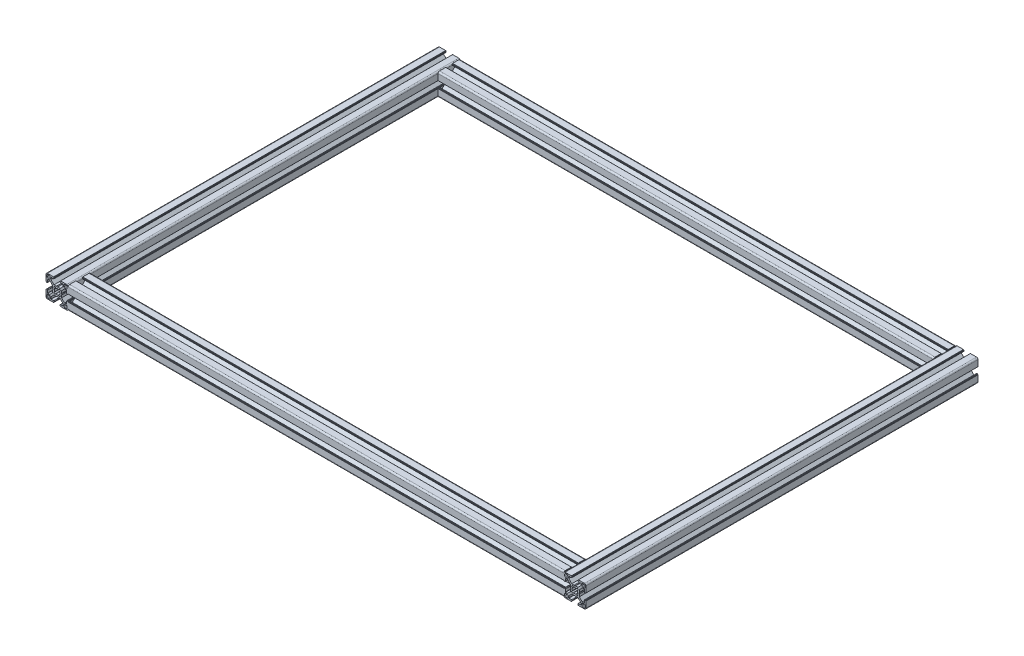
from build123d import *

# Parameters (mm, degrees)
BOSS_EXTRUDE1_DEPTH   = 265
BOSS_EXTRUDE1_2_DEPTH = 265
BOSS_EXTRUDE2_DEPTH   = 335


with BuildPart() as part:
    # Sketch13 → Boss-Extrude1 (new body, symmetric)
    with BuildSketch(Plane.XY):
        with BuildLine():
            Line((356.00446543, 0.899999619), (355.484852164, 0))
            Line((355.484852164, 0), (356.00446543, -0.899999619))
            Line((356.00446543, -0.899999619), (356.00446543, -4.204465866))
            Line((356.00446543, -4.204465866), (360.049999564, -8.25))
            Line((360.049999564, -8.25), (362.59999928, -8.25))
            ThreePointArc((362.59999928, -8.25), (362.741420837, -8.191421273), (362.799999564, -8.049999716))
            Line((362.799999564, -8.049999716), (362.799999564, -4.649999613))
            ThreePointArc((362.799999564, -4.649999613), (362.975735606, -4.225735278), (363.39999994, -4.049999237))
            Line((363.39999994, -4.049999237), (364.300000043, -4.049999237))
            ThreePointArc((364.300000043, -4.049999237), (364.4414216, -4.108577964), (364.500000327, -4.249999521))
            Line((364.500000327, -4.249999521), (364.500000327, -4.349998953))
            ThreePointArc((364.500000327, -4.349998953), (364.558579054, -4.49142051), (364.700000611, -4.549999237))
            Line((364.700000611, -4.549999237), (364.799999716, -4.549999237))
            ThreePointArc((364.799999716, -4.549999237), (364.941421273, -4.608577964), (365, -4.749999521))
            Line((365, -4.749999521), (365, -13.000000346))
            ThreePointArc((365, -13.000000346), (364.414213664, -14.414213664), (363.000000346, -15))
            Line((363.000000346, -15), (354.749999945, -15))
            ThreePointArc((354.749999945, -15), (354.60857832, -14.941421245), (354.549999564, -14.799999619))
            Line((354.549999564, -14.799999619), (354.549999564, -14.69999942))
            ThreePointArc((354.549999564, -14.69999942), (354.49142109, -14.558578474), (354.350000144, -14.5))
            Line((354.350000144, -14.5), (354.250000374, -14.5))
            ThreePointArc((354.250000374, -14.5), (354.108578753, -14.441421247), (354.05, -14.299999626))
            Line((354.05, -14.299999626), (354.05, -13.399999434))
            ThreePointArc((354.05, -13.399999434), (354.225735989, -12.975735226), (354.650000197, -12.799999237))
            Line((354.650000197, -12.799999237), (358.049999924, -12.799999237))
            ThreePointArc((358.049999924, -12.799999237), (358.191421565, -12.741420475), (358.250000327, -12.599998834))
            Line((358.250000327, -12.599998834), (358.250000327, -10.049999237))
            Line((358.250000327, -10.049999237), (354.204466193, -6))
            Line((354.204466193, -6), (350.899999946, -6))
            Line((350.899999946, -6), (350, -5.484851837))
            Line((350, -5.484851837), (349.100000054, -6))
            Line((349.100000054, -6), (345.795533807, -6))
            Line((345.795533807, -6), (341.749999673, -10.049999237))
            Line((341.749999673, -10.049999237), (341.749999673, -12.599998834))
            ThreePointArc((341.749999673, -12.599998834), (341.808578435, -12.741420475), (341.950000076, -12.799999237))
            Line((341.950000076, -12.799999237), (345.349999803, -12.799999237))
            ThreePointArc((345.349999803, -12.799999237), (345.774264011, -12.975735226), (345.95, -13.399999434))
            Line((345.95, -13.399999434), (345.95, -14.299999626))
            ThreePointArc((345.95, -14.299999626), (345.891421247, -14.441421247), (345.749999626, -14.5))
            Line((345.749999626, -14.5), (345.649999856, -14.5))
            ThreePointArc((345.649999856, -14.5), (345.50857891, -14.558578474), (345.450000436, -14.69999942))
            Line((345.450000436, -14.69999942), (345.450000436, -14.799999619))
            ThreePointArc((345.450000436, -14.799999619), (345.39142168, -14.941421245), (345.250000055, -15))
            Line((345.250000055, -15), (336.999999654, -15))
            ThreePointArc((336.999999654, -15), (335.585786336, -14.414213664), (335, -13.000000346))
            Line((335, -13.000000346), (335, -4.749999521))
            ThreePointArc((335, -4.749999521), (335.058578727, -4.608577964), (335.200000284, -4.549999237))
            Line((335.200000284, -4.549999237), (335.299999389, -4.549999237))
            ThreePointArc((335.299999389, -4.549999237), (335.441420946, -4.49142051), (335.499999673, -4.349998953))
            Line((335.499999673, -4.349998953), (335.499999673, -4.249999521))
            ThreePointArc((335.499999673, -4.249999521), (335.5585784, -4.108577964), (335.699999957, -4.049999237))
            Line((335.699999957, -4.049999237), (336.60000006, -4.049999237))
            ThreePointArc((336.60000006, -4.049999237), (337.024264394, -4.225735278), (337.200000436, -4.649999613))
            Line((337.200000436, -4.649999613), (337.200000436, -8.049999716))
            ThreePointArc((337.200000436, -8.049999716), (337.258579163, -8.191421273), (337.40000072, -8.25))
            Line((337.40000072, -8.25), (339.950000436, -8.25))
            Line((339.950000436, -8.25), (343.99553457, -4.204465866))
            Line((343.99553457, -4.204465866), (343.99553457, -0.899999619))
            Line((343.99553457, -0.899999619), (344.515147836, 0))
            Line((344.515147836, 0), (343.99553457, 0.899999619))
            Line((343.99553457, 0.899999619), (343.99553457, 4.204465866))
            Line((343.99553457, 4.204465866), (339.950000436, 8.25))
            Line((339.950000436, 8.25), (337.40000072, 8.25))
            ThreePointArc((337.40000072, 8.25), (337.258579163, 8.191421273), (337.200000436, 8.049999716))
            Line((337.200000436, 8.049999716), (337.200000436, 4.649999613))
            ThreePointArc((337.200000436, 4.649999613), (337.024264394, 4.225735278), (336.60000006, 4.049999237))
            Line((336.60000006, 4.049999237), (335.699999957, 4.049999237))
            ThreePointArc((335.699999957, 4.049999237), (335.5585784, 4.108577964), (335.499999673, 4.249999521))
            Line((335.499999673, 4.249999521), (335.499999673, 4.349998953))
            ThreePointArc((335.499999673, 4.349998953), (335.441420946, 4.49142051), (335.299999389, 4.549999237))
            Line((335.299999389, 4.549999237), (335.200000284, 4.549999237))
            ThreePointArc((335.200000284, 4.549999237), (335.058578727, 4.608577964), (335, 4.749999521))
            Line((335, 4.749999521), (335, 13.000000346))
            ThreePointArc((335, 13.000000346), (335.585786336, 14.414213664), (336.999999654, 15))
            Line((336.999999654, 15), (345.250000055, 15))
            ThreePointArc((345.250000055, 15), (345.39142168, 14.941421245), (345.450000436, 14.799999619))
            Line((345.450000436, 14.799999619), (345.450000436, 14.69999942))
            ThreePointArc((345.450000436, 14.69999942), (345.50857891, 14.558578474), (345.649999856, 14.5))
            Line((345.649999856, 14.5), (345.749999626, 14.5))
            ThreePointArc((345.749999626, 14.5), (345.891421247, 14.441421247), (345.95, 14.299999626))
            Line((345.95, 14.299999626), (345.95, 13.399999434))
            ThreePointArc((345.95, 13.399999434), (345.774264011, 12.975735226), (345.349999803, 12.799999237))
            Line((345.349999803, 12.799999237), (341.950000076, 12.799999237))
            ThreePointArc((341.950000076, 12.799999237), (341.808578435, 12.741420475), (341.749999673, 12.599998834))
            Line((341.749999673, 12.599998834), (341.749999673, 10.049999237))
            Line((341.749999673, 10.049999237), (345.795533807, 6))
            Line((345.795533807, 6), (349.100000054, 6))
            Line((349.100000054, 6), (350, 5.484851837))
            Line((350, 5.484851837), (350.899999946, 6))
            Line((350.899999946, 6), (354.204466193, 6))
            Line((354.204466193, 6), (358.250000327, 10.049999237))
            Line((358.250000327, 10.049999237), (358.250000327, 12.599998834))
            ThreePointArc((358.250000327, 12.599998834), (358.191421565, 12.741420475), (358.049999924, 12.799999237))
            Line((358.049999924, 12.799999237), (354.650000197, 12.799999237))
            ThreePointArc((354.650000197, 12.799999237), (354.225735989, 12.975735226), (354.05, 13.399999434))
            Line((354.05, 13.399999434), (354.05, 14.299999626))
            ThreePointArc((354.05, 14.299999626), (354.108578753, 14.441421247), (354.250000374, 14.5))
            Line((354.250000374, 14.5), (354.350000144, 14.5))
            ThreePointArc((354.350000144, 14.5), (354.49142109, 14.558578474), (354.549999564, 14.69999942))
            Line((354.549999564, 14.69999942), (354.549999564, 14.799999619))
            ThreePointArc((354.549999564, 14.799999619), (354.60857832, 14.941421245), (354.749999945, 15))
            Line((354.749999945, 15), (363.000000346, 15))
            ThreePointArc((363.000000346, 15), (364.414213664, 14.414213664), (365, 13.000000346))
            Line((365, 13.000000346), (365, 4.749999521))
            ThreePointArc((365, 4.749999521), (364.941421273, 4.608577964), (364.799999716, 4.549999237))
            Line((364.799999716, 4.549999237), (364.700000611, 4.549999237))
            ThreePointArc((364.700000611, 4.549999237), (364.558579054, 4.49142051), (364.500000327, 4.349998953))
            Line((364.500000327, 4.349998953), (364.500000327, 4.249999521))
            ThreePointArc((364.500000327, 4.249999521), (364.4414216, 4.108577964), (364.300000043, 4.049999237))
            Line((364.300000043, 4.049999237), (363.39999994, 4.049999237))
            ThreePointArc((363.39999994, 4.049999237), (362.975735606, 4.225735278), (362.799999564, 4.649999613))
            Line((362.799999564, 4.649999613), (362.799999564, 8.049999716))
            ThreePointArc((362.799999564, 8.049999716), (362.741420837, 8.191421273), (362.59999928, 8.25))
            Line((362.59999928, 8.25), (360.049999564, 8.25))
            Line((360.049999564, 8.25), (356.00446543, 4.204465866))
            Line((356.00446543, 4.204465866), (356.00446543, 0.899999619))
        make_face()
        with BuildLine():
            Line((363.70000109, 12.700000408), (363.70000109, 10.499999626))
            ThreePointArc((363.70000109, 10.499999626), (363.407107874, 9.792892851), (362.7000011, 9.499999635))
            Line((362.7000011, 9.499999635), (360.500000318, 9.499999635))
            ThreePointArc((360.500000318, 9.499999635), (359.792893543, 9.792892851), (359.500000327, 10.499999626))
            Line((359.500000327, 10.499999626), (359.500000327, 12.700000408))
            ThreePointArc((359.500000327, 12.700000408), (359.792893543, 13.407107182), (360.500000318, 13.700000398))
            Line((360.500000318, 13.700000398), (362.7000011, 13.700000398))
            ThreePointArc((362.7000011, 13.700000398), (363.407107874, 13.407107182), (363.70000109, 12.700000408))
        make_face(mode=Mode.SUBTRACT)
        with BuildLine():
            Line((353.135929412, 4.518400903), (351.600129524, 3.280561767))
            ThreePointArc((351.600129524, 3.280561767), (350, 3.65), (348.399870476, 3.280561767))
            Line((348.399870476, 3.280561767), (346.864070588, 4.518400903))
            ThreePointArc((346.864070588, 4.518400903), (346.118997741, 3.897155561), (345.494663108, 3.154669473))
            Line((345.494663108, 3.154669473), (346.719438268, 1.600129597))
            ThreePointArc((346.719438268, 1.600129597), (346.35, 0), (346.719438268, -1.600129597))
            Line((346.719438268, -1.600129597), (345.494663108, -3.154669473))
            ThreePointArc((345.494663108, -3.154669473), (346.118997741, -3.897155561), (346.864070588, -4.518400903))
            Line((346.864070588, -4.518400903), (348.399870476, -3.280561767))
            ThreePointArc((348.399870476, -3.280561767), (350, -3.65), (351.600129524, -3.280561767))
            Line((351.600129524, -3.280561767), (353.135929412, -4.518400903))
            ThreePointArc((353.135929412, -4.518400903), (353.881002259, -3.897155561), (354.505336892, -3.154669473))
            Line((354.505336892, -3.154669473), (353.280561732, -1.600129597))
            ThreePointArc((353.280561732, -1.600129597), (353.65, 0), (353.280561732, 1.600129597))
            Line((353.280561732, 1.600129597), (354.505336892, 3.154669473))
            ThreePointArc((354.505336892, 3.154669473), (353.881002259, 3.897155561), (353.135929412, 4.518400903))
        make_face(mode=Mode.SUBTRACT)
        with BuildLine():
            Line((336.29999891, -12.700000408), (336.29999891, -10.499999626))
            ThreePointArc((336.29999891, -10.499999626), (336.592892126, -9.792892851), (337.2999989, -9.499999635))
            Line((337.2999989, -9.499999635), (339.499999682, -9.499999635))
            ThreePointArc((339.499999682, -9.499999635), (340.207106457, -9.792892851), (340.499999673, -10.499999626))
            Line((340.499999673, -10.499999626), (340.499999673, -12.700000408))
            ThreePointArc((340.499999673, -12.700000408), (340.207106457, -13.407107182), (339.499999682, -13.700000398))
            Line((339.499999682, -13.700000398), (337.2999989, -13.700000398))
            ThreePointArc((337.2999989, -13.700000398), (336.592892126, -13.407107182), (336.29999891, -12.700000408))
        make_face(mode=Mode.SUBTRACT)
        with BuildLine():
            Line((360.500000318, -13.700000398), (362.7000011, -13.700000398))
            ThreePointArc((362.7000011, -13.700000398), (363.407107874, -13.407107182), (363.70000109, -12.700000408))
            Line((363.70000109, -12.700000408), (363.70000109, -10.499999626))
            ThreePointArc((363.70000109, -10.499999626), (363.407107874, -9.792892851), (362.7000011, -9.499999635))
            Line((362.7000011, -9.499999635), (360.500000318, -9.499999635))
            ThreePointArc((360.500000318, -9.499999635), (359.792893543, -9.792892851), (359.500000327, -10.499999626))
            Line((359.500000327, -10.499999626), (359.500000327, -12.700000408))
            ThreePointArc((359.500000327, -12.700000408), (359.792893543, -13.407107182), (360.500000318, -13.700000398))
        make_face(mode=Mode.SUBTRACT)
        with BuildLine():
            Line((339.499999682, 13.700000398), (337.2999989, 13.700000398))
            ThreePointArc((337.2999989, 13.700000398), (336.592892126, 13.407107182), (336.29999891, 12.700000408))
            Line((336.29999891, 12.700000408), (336.29999891, 10.499999626))
            ThreePointArc((336.29999891, 10.499999626), (336.592892126, 9.792892851), (337.2999989, 9.499999635))
            Line((337.2999989, 9.499999635), (339.499999682, 9.499999635))
            ThreePointArc((339.499999682, 9.499999635), (340.207106457, 9.792892851), (340.499999673, 10.499999626))
            Line((340.499999673, 10.499999626), (340.499999673, 12.700000408))
            ThreePointArc((340.499999673, 12.700000408), (340.207106457, 13.407107182), (339.499999682, 13.700000398))
        make_face(mode=Mode.SUBTRACT)
    extrude(amount=BOSS_EXTRUDE1_DEPTH, both=True)



with BuildPart() as body_2:
    # Sketch13 → Boss-Extrude1 2 (new body, symmetric)
    with BuildSketch(Plane.XY):
        with BuildLine():
            Line((-337.40000072, 8.25), (-339.950000436, 8.25))
            Line((-339.950000436, 8.25), (-343.99553457, 4.204465866))
            Line((-343.99553457, 4.204465866), (-343.99553457, 0.899999619))
            Line((-343.99553457, 0.899999619), (-344.515147836, 0))
            Line((-344.515147836, 0), (-343.99553457, -0.899999619))
            Line((-343.99553457, -0.899999619), (-343.99553457, -4.204465866))
            Line((-343.99553457, -4.204465866), (-339.950000436, -8.25))
            Line((-339.950000436, -8.25), (-337.40000072, -8.25))
            ThreePointArc((-337.40000072, -8.25), (-337.258579163, -8.191421273), (-337.200000436, -8.049999716))
            Line((-337.200000436, -8.049999716), (-337.200000436, -4.649999613))
            ThreePointArc((-337.200000436, -4.649999613), (-337.024264394, -4.225735278), (-336.60000006, -4.049999237))
            Line((-336.60000006, -4.049999237), (-335.699999957, -4.049999237))
            ThreePointArc((-335.699999957, -4.049999237), (-335.5585784, -4.108577964), (-335.499999673, -4.249999521))
            Line((-335.499999673, -4.249999521), (-335.499999673, -4.349998953))
            ThreePointArc((-335.499999673, -4.349998953), (-335.441420946, -4.49142051), (-335.299999389, -4.549999237))
            Line((-335.299999389, -4.549999237), (-335.200000284, -4.549999237))
            ThreePointArc((-335.200000284, -4.549999237), (-335.058578727, -4.608577964), (-335, -4.749999521))
            Line((-335, -4.749999521), (-335, -13.000000346))
            ThreePointArc((-335, -13.000000346), (-335.585786336, -14.414213664), (-336.999999654, -15))
            Line((-336.999999654, -15), (-345.250000055, -15))
            ThreePointArc((-345.250000055, -15), (-345.39142168, -14.941421245), (-345.450000436, -14.799999619))
            Line((-345.450000436, -14.799999619), (-345.450000436, -14.69999942))
            ThreePointArc((-345.450000436, -14.69999942), (-345.50857891, -14.558578474), (-345.649999856, -14.5))
            Line((-345.649999856, -14.5), (-345.749999626, -14.5))
            ThreePointArc((-345.749999626, -14.5), (-345.891421247, -14.441421247), (-345.95, -14.299999626))
            Line((-345.95, -14.299999626), (-345.95, -13.399999434))
            ThreePointArc((-345.95, -13.399999434), (-345.774264011, -12.975735226), (-345.349999803, -12.799999237))
            Line((-345.349999803, -12.799999237), (-341.950000076, -12.799999237))
            ThreePointArc((-341.950000076, -12.799999237), (-341.808578435, -12.741420475), (-341.749999673, -12.599998834))
            Line((-341.749999673, -12.599998834), (-341.749999673, -10.049999237))
            Line((-341.749999673, -10.049999237), (-345.795533807, -6))
            Line((-345.795533807, -6), (-349.100000054, -6))
            Line((-349.100000054, -6), (-350, -5.484851837))
            Line((-350, -5.484851837), (-350.899999946, -6))
            Line((-350.899999946, -6), (-354.204466193, -6))
            Line((-354.204466193, -6), (-358.250000327, -10.049999237))
            Line((-358.250000327, -10.049999237), (-358.250000327, -12.599998834))
            ThreePointArc((-358.250000327, -12.599998834), (-358.191421565, -12.741420475), (-358.049999924, -12.799999237))
            Line((-358.049999924, -12.799999237), (-354.650000197, -12.799999237))
            ThreePointArc((-354.650000197, -12.799999237), (-354.225735989, -12.975735226), (-354.05, -13.399999434))
            Line((-354.05, -13.399999434), (-354.05, -14.299999626))
            ThreePointArc((-354.05, -14.299999626), (-354.108578753, -14.441421247), (-354.250000374, -14.5))
            Line((-354.250000374, -14.5), (-354.350000144, -14.5))
            ThreePointArc((-354.350000144, -14.5), (-354.49142109, -14.558578474), (-354.549999564, -14.69999942))
            Line((-354.549999564, -14.69999942), (-354.549999564, -14.799999619))
            ThreePointArc((-354.549999564, -14.799999619), (-354.60857832, -14.941421245), (-354.749999945, -15))
            Line((-354.749999945, -15), (-363.000000346, -15))
            ThreePointArc((-363.000000346, -15), (-364.414213664, -14.414213664), (-365, -13.000000346))
            Line((-365, -13.000000346), (-365, -4.749999521))
            ThreePointArc((-365, -4.749999521), (-364.941421273, -4.608577964), (-364.799999716, -4.549999237))
            Line((-364.799999716, -4.549999237), (-364.700000611, -4.549999237))
            ThreePointArc((-364.700000611, -4.549999237), (-364.558579054, -4.49142051), (-364.500000327, -4.349998953))
            Line((-364.500000327, -4.349998953), (-364.500000327, -4.249999521))
            ThreePointArc((-364.500000327, -4.249999521), (-364.4414216, -4.108577964), (-364.300000043, -4.049999237))
            Line((-364.300000043, -4.049999237), (-363.39999994, -4.049999237))
            ThreePointArc((-363.39999994, -4.049999237), (-362.975735606, -4.225735278), (-362.799999564, -4.649999613))
            Line((-362.799999564, -4.649999613), (-362.799999564, -8.049999716))
            ThreePointArc((-362.799999564, -8.049999716), (-362.741420837, -8.191421273), (-362.59999928, -8.25))
            Line((-362.59999928, -8.25), (-360.049999564, -8.25))
            Line((-360.049999564, -8.25), (-356.00446543, -4.204465866))
            Line((-356.00446543, -4.204465866), (-356.00446543, -0.899999619))
            Line((-356.00446543, -0.899999619), (-355.484852164, 0))
            Line((-355.484852164, 0), (-356.00446543, 0.899999619))
            Line((-356.00446543, 0.899999619), (-356.00446543, 4.204465866))
            Line((-356.00446543, 4.204465866), (-360.049999564, 8.25))
            Line((-360.049999564, 8.25), (-362.59999928, 8.25))
            ThreePointArc((-362.59999928, 8.25), (-362.741420837, 8.191421273), (-362.799999564, 8.049999716))
            Line((-362.799999564, 8.049999716), (-362.799999564, 4.649999613))
            ThreePointArc((-362.799999564, 4.649999613), (-362.975735606, 4.225735278), (-363.39999994, 4.049999237))
            Line((-363.39999994, 4.049999237), (-364.300000043, 4.049999237))
            ThreePointArc((-364.300000043, 4.049999237), (-364.4414216, 4.108577964), (-364.500000327, 4.249999521))
            Line((-364.500000327, 4.249999521), (-364.500000327, 4.349998953))
            ThreePointArc((-364.500000327, 4.349998953), (-364.558579054, 4.49142051), (-364.700000611, 4.549999237))
            Line((-364.700000611, 4.549999237), (-364.799999716, 4.549999237))
            ThreePointArc((-364.799999716, 4.549999237), (-364.941421273, 4.608577964), (-365, 4.749999521))
            Line((-365, 4.749999521), (-365, 13.000000346))
            ThreePointArc((-365, 13.000000346), (-364.414213664, 14.414213664), (-363.000000346, 15))
            Line((-363.000000346, 15), (-354.749999945, 15))
            ThreePointArc((-354.749999945, 15), (-354.60857832, 14.941421245), (-354.549999564, 14.799999619))
            Line((-354.549999564, 14.799999619), (-354.549999564, 14.69999942))
            ThreePointArc((-354.549999564, 14.69999942), (-354.49142109, 14.558578474), (-354.350000144, 14.5))
            Line((-354.350000144, 14.5), (-354.250000374, 14.5))
            ThreePointArc((-354.250000374, 14.5), (-354.108578753, 14.441421247), (-354.05, 14.299999626))
            Line((-354.05, 14.299999626), (-354.05, 13.399999434))
            ThreePointArc((-354.05, 13.399999434), (-354.225735989, 12.975735226), (-354.650000197, 12.799999237))
            Line((-354.650000197, 12.799999237), (-358.049999924, 12.799999237))
            ThreePointArc((-358.049999924, 12.799999237), (-358.191421565, 12.741420475), (-358.250000327, 12.599998834))
            Line((-358.250000327, 12.599998834), (-358.250000327, 10.049999237))
            Line((-358.250000327, 10.049999237), (-354.204466193, 6))
            Line((-354.204466193, 6), (-350.899999946, 6))
            Line((-350.899999946, 6), (-350, 5.484851837))
            Line((-350, 5.484851837), (-349.100000054, 6))
            Line((-349.100000054, 6), (-345.795533807, 6))
            Line((-345.795533807, 6), (-341.749999673, 10.049999237))
            Line((-341.749999673, 10.049999237), (-341.749999673, 12.599998834))
            ThreePointArc((-341.749999673, 12.599998834), (-341.808578435, 12.741420475), (-341.950000076, 12.799999237))
            Line((-341.950000076, 12.799999237), (-345.349999803, 12.799999237))
            ThreePointArc((-345.349999803, 12.799999237), (-345.774264011, 12.975735226), (-345.95, 13.399999434))
            Line((-345.95, 13.399999434), (-345.95, 14.299999626))
            ThreePointArc((-345.95, 14.299999626), (-345.891421247, 14.441421247), (-345.749999626, 14.5))
            Line((-345.749999626, 14.5), (-345.649999856, 14.5))
            ThreePointArc((-345.649999856, 14.5), (-345.50857891, 14.558578474), (-345.450000436, 14.69999942))
            Line((-345.450000436, 14.69999942), (-345.450000436, 14.799999619))
            ThreePointArc((-345.450000436, 14.799999619), (-345.39142168, 14.941421245), (-345.250000055, 15))
            Line((-345.250000055, 15), (-336.999999654, 15))
            ThreePointArc((-336.999999654, 15), (-335.585786336, 14.414213664), (-335, 13.000000346))
            Line((-335, 13.000000346), (-335, 4.749999521))
            ThreePointArc((-335, 4.749999521), (-335.058578727, 4.608577964), (-335.200000284, 4.549999237))
            Line((-335.200000284, 4.549999237), (-335.299999389, 4.549999237))
            ThreePointArc((-335.299999389, 4.549999237), (-335.441420946, 4.49142051), (-335.499999673, 4.349998953))
            Line((-335.499999673, 4.349998953), (-335.499999673, 4.249999521))
            ThreePointArc((-335.499999673, 4.249999521), (-335.5585784, 4.108577964), (-335.699999957, 4.049999237))
            Line((-335.699999957, 4.049999237), (-336.60000006, 4.049999237))
            ThreePointArc((-336.60000006, 4.049999237), (-337.024264394, 4.225735278), (-337.200000436, 4.649999613))
            Line((-337.200000436, 4.649999613), (-337.200000436, 8.049999716))
            ThreePointArc((-337.200000436, 8.049999716), (-337.258579163, 8.191421273), (-337.40000072, 8.25))
        make_face()
        with BuildLine():
            Line((-336.29999891, -12.700000408), (-336.29999891, -10.499999626))
            ThreePointArc((-336.29999891, -10.499999626), (-336.592892126, -9.792892851), (-337.2999989, -9.499999635))
            Line((-337.2999989, -9.499999635), (-339.499999682, -9.499999635))
            ThreePointArc((-339.499999682, -9.499999635), (-340.207106457, -9.792892851), (-340.499999673, -10.499999626))
            Line((-340.499999673, -10.499999626), (-340.499999673, -12.700000408))
            ThreePointArc((-340.499999673, -12.700000408), (-340.207106457, -13.407107182), (-339.499999682, -13.700000398))
            Line((-339.499999682, -13.700000398), (-337.2999989, -13.700000398))
            ThreePointArc((-337.2999989, -13.700000398), (-336.592892126, -13.407107182), (-336.29999891, -12.700000408))
        make_face(mode=Mode.SUBTRACT)
        with BuildLine():
            Line((-346.719438268, 1.600129597), (-345.494663108, 3.154669473))
            ThreePointArc((-345.494663108, 3.154669473), (-346.118997741, 3.897155561), (-346.864070588, 4.518400903))
            Line((-346.864070588, 4.518400903), (-348.399870476, 3.280561767))
            ThreePointArc((-348.399870476, 3.280561767), (-350, 3.65), (-351.600129524, 3.280561767))
            Line((-351.600129524, 3.280561767), (-353.135929412, 4.518400903))
            ThreePointArc((-353.135929412, 4.518400903), (-353.881002259, 3.897155561), (-354.505336892, 3.154669473))
            Line((-354.505336892, 3.154669473), (-353.280561732, 1.600129597))
            ThreePointArc((-353.280561732, 1.600129597), (-353.65, 0), (-353.280561732, -1.600129597))
            Line((-353.280561732, -1.600129597), (-354.505336892, -3.154669473))
            ThreePointArc((-354.505336892, -3.154669473), (-353.881002259, -3.897155561), (-353.135929412, -4.518400903))
            Line((-353.135929412, -4.518400903), (-351.600129524, -3.280561767))
            ThreePointArc((-351.600129524, -3.280561767), (-350, -3.65), (-348.399870476, -3.280561767))
            Line((-348.399870476, -3.280561767), (-346.864070588, -4.518400903))
            ThreePointArc((-346.864070588, -4.518400903), (-346.118997741, -3.897155561), (-345.494663108, -3.154669473))
            Line((-345.494663108, -3.154669473), (-346.719438268, -1.600129597))
            ThreePointArc((-346.719438268, -1.600129597), (-346.35, 0), (-346.719438268, 1.600129597))
        make_face(mode=Mode.SUBTRACT)
        with BuildLine():
            Line((-336.29999891, 12.700000408), (-336.29999891, 10.499999626))
            ThreePointArc((-336.29999891, 10.499999626), (-336.592892126, 9.792892851), (-337.2999989, 9.499999635))
            Line((-337.2999989, 9.499999635), (-339.499999682, 9.499999635))
            ThreePointArc((-339.499999682, 9.499999635), (-340.207106457, 9.792892851), (-340.499999673, 10.499999626))
            Line((-340.499999673, 10.499999626), (-340.499999673, 12.700000408))
            ThreePointArc((-340.499999673, 12.700000408), (-340.207106457, 13.407107182), (-339.499999682, 13.700000398))
            Line((-339.499999682, 13.700000398), (-337.2999989, 13.700000398))
            ThreePointArc((-337.2999989, 13.700000398), (-336.592892126, 13.407107182), (-336.29999891, 12.700000408))
        make_face(mode=Mode.SUBTRACT)
        with BuildLine():
            Line((-359.500000327, -12.700000408), (-359.500000327, -10.499999626))
            ThreePointArc((-359.500000327, -10.499999626), (-359.792893543, -9.792892851), (-360.500000318, -9.499999635))
            Line((-360.500000318, -9.499999635), (-362.7000011, -9.499999635))
            ThreePointArc((-362.7000011, -9.499999635), (-363.407107874, -9.792892851), (-363.70000109, -10.499999626))
            Line((-363.70000109, -10.499999626), (-363.70000109, -12.700000408))
            ThreePointArc((-363.70000109, -12.700000408), (-363.407107874, -13.407107182), (-362.7000011, -13.700000398))
            Line((-362.7000011, -13.700000398), (-360.500000318, -13.700000398))
            ThreePointArc((-360.500000318, -13.700000398), (-359.792893543, -13.407107182), (-359.500000327, -12.700000408))
        make_face(mode=Mode.SUBTRACT)
        with BuildLine():
            Line((-363.70000109, 12.700000408), (-363.70000109, 10.499999626))
            ThreePointArc((-363.70000109, 10.499999626), (-363.407107874, 9.792892851), (-362.7000011, 9.499999635))
            Line((-362.7000011, 9.499999635), (-360.500000318, 9.499999635))
            ThreePointArc((-360.500000318, 9.499999635), (-359.792893543, 9.792892851), (-359.500000327, 10.499999626))
            Line((-359.500000327, 10.499999626), (-359.500000327, 12.700000408))
            ThreePointArc((-359.500000327, 12.700000408), (-359.792893543, 13.407107182), (-360.500000318, 13.700000398))
            Line((-360.500000318, 13.700000398), (-362.7000011, 13.700000398))
            ThreePointArc((-362.7000011, 13.700000398), (-363.407107874, 13.407107182), (-363.70000109, 12.700000408))
        make_face(mode=Mode.SUBTRACT)
    extrude(amount=BOSS_EXTRUDE1_2_DEPTH, both=True)


with BuildPart() as part_1:
    add(part.part)

    add(body_2.part)  # Boss-Extrude2 merges body 2
    # Sketch14 → Boss-Extrude2 (add, symmetric)
    with BuildSketch(Plane(origin=(0, 0, 0), x_dir=(0, 0, -1), z_dir=(1, 0, 0))):
        with BuildLine():
            Line((-235.299999389, 4.549999237), (-235.200000284, 4.549999237))
            ThreePointArc((-235.200000284, 4.549999237), (-235.058578727, 4.608577964), (-235, 4.749999521))
            Line((-235, 4.749999521), (-235, 13.000000346))
            ThreePointArc((-235, 13.000000346), (-235.585786336, 14.414213664), (-236.999999654, 15))
            Line((-236.999999654, 15), (-245.250000055, 15))
            ThreePointArc((-245.250000055, 15), (-245.39142168, 14.941421245), (-245.450000436, 14.799999619))
            Line((-245.450000436, 14.799999619), (-245.450000436, 14.69999942))
            ThreePointArc((-245.450000436, 14.69999942), (-245.50857891, 14.558578474), (-245.649999856, 14.5))
            Line((-245.649999856, 14.5), (-245.749999626, 14.5))
            ThreePointArc((-245.749999626, 14.5), (-245.891421247, 14.441421247), (-245.95, 14.299999626))
            Line((-245.95, 14.299999626), (-245.95, 13.399999434))
            ThreePointArc((-245.95, 13.399999434), (-245.774264011, 12.975735226), (-245.349999803, 12.799999237))
            Line((-245.349999803, 12.799999237), (-241.950000076, 12.799999237))
            ThreePointArc((-241.950000076, 12.799999237), (-241.808578435, 12.741420475), (-241.749999673, 12.599998834))
            Line((-241.749999673, 12.599998834), (-241.749999673, 10.049999237))
            Line((-241.749999673, 10.049999237), (-245.795533807, 6))
            Line((-245.795533807, 6), (-249.100000054, 6))
            Line((-249.100000054, 6), (-250, 5.484851837))
            Line((-250, 5.484851837), (-250.899999946, 6))
            Line((-250.899999946, 6), (-254.204466193, 6))
            Line((-254.204466193, 6), (-258.250000327, 10.049999237))
            Line((-258.250000327, 10.049999237), (-258.250000327, 12.599998834))
            ThreePointArc((-258.250000327, 12.599998834), (-258.191421565, 12.741420475), (-258.049999924, 12.799999237))
            Line((-258.049999924, 12.799999237), (-254.650000197, 12.799999237))
            ThreePointArc((-254.650000197, 12.799999237), (-254.225735989, 12.975735226), (-254.05, 13.399999434))
            Line((-254.05, 13.399999434), (-254.05, 14.299999626))
            ThreePointArc((-254.05, 14.299999626), (-254.108578753, 14.441421247), (-254.250000374, 14.5))
            Line((-254.250000374, 14.5), (-254.350000144, 14.5))
            ThreePointArc((-254.350000144, 14.5), (-254.49142109, 14.558578474), (-254.549999564, 14.69999942))
            Line((-254.549999564, 14.69999942), (-254.549999564, 14.799999619))
            ThreePointArc((-254.549999564, 14.799999619), (-254.60857832, 14.941421245), (-254.749999945, 15))
            Line((-254.749999945, 15), (-263.000000346, 15))
            ThreePointArc((-263.000000346, 15), (-264.414213664, 14.414213664), (-265, 13.000000346))
            Line((-265, 13.000000346), (-265, 4.749999521))
            ThreePointArc((-265, 4.749999521), (-264.941421273, 4.608577964), (-264.799999716, 4.549999237))
            Line((-264.799999716, 4.549999237), (-264.700000611, 4.549999237))
            ThreePointArc((-264.700000611, 4.549999237), (-264.558579054, 4.49142051), (-264.500000327, 4.349998953))
            Line((-264.500000327, 4.349998953), (-264.500000327, 4.249999521))
            ThreePointArc((-264.500000327, 4.249999521), (-264.4414216, 4.108577964), (-264.300000043, 4.049999237))
            Line((-264.300000043, 4.049999237), (-263.39999994, 4.049999237))
            ThreePointArc((-263.39999994, 4.049999237), (-262.975735606, 4.225735278), (-262.799999564, 4.649999613))
            Line((-262.799999564, 4.649999613), (-262.799999564, 8.049999716))
            ThreePointArc((-262.799999564, 8.049999716), (-262.741420837, 8.191421273), (-262.59999928, 8.25))
            Line((-262.59999928, 8.25), (-260.049999564, 8.25))
            Line((-260.049999564, 8.25), (-256.00446543, 4.204465866))
            Line((-256.00446543, 4.204465866), (-256.00446543, 0.899999619))
            Line((-256.00446543, 0.899999619), (-255.484852164, 0))
            Line((-255.484852164, 0), (-256.00446543, -0.899999619))
            Line((-256.00446543, -0.899999619), (-256.00446543, -4.204465866))
            Line((-256.00446543, -4.204465866), (-260.049999564, -8.25))
            Line((-260.049999564, -8.25), (-262.59999928, -8.25))
            ThreePointArc((-262.59999928, -8.25), (-262.741420837, -8.191421273), (-262.799999564, -8.049999716))
            Line((-262.799999564, -8.049999716), (-262.799999564, -4.649999613))
            ThreePointArc((-262.799999564, -4.649999613), (-262.975735606, -4.225735278), (-263.39999994, -4.049999237))
            Line((-263.39999994, -4.049999237), (-264.300000043, -4.049999237))
            ThreePointArc((-264.300000043, -4.049999237), (-264.4414216, -4.108577964), (-264.500000327, -4.249999521))
            Line((-264.500000327, -4.249999521), (-264.500000327, -4.349998953))
            ThreePointArc((-264.500000327, -4.349998953), (-264.558579054, -4.49142051), (-264.700000611, -4.549999237))
            Line((-264.700000611, -4.549999237), (-264.799999716, -4.549999237))
            ThreePointArc((-264.799999716, -4.549999237), (-264.941421273, -4.608577964), (-265, -4.749999521))
            Line((-265, -4.749999521), (-265, -13.000000346))
            ThreePointArc((-265, -13.000000346), (-264.414213664, -14.414213664), (-263.000000346, -15))
            Line((-263.000000346, -15), (-254.749999945, -15))
            ThreePointArc((-254.749999945, -15), (-254.60857832, -14.941421245), (-254.549999564, -14.799999619))
            Line((-254.549999564, -14.799999619), (-254.549999564, -14.69999942))
            ThreePointArc((-254.549999564, -14.69999942), (-254.49142109, -14.558578474), (-254.350000144, -14.5))
            Line((-254.350000144, -14.5), (-254.250000374, -14.5))
            ThreePointArc((-254.250000374, -14.5), (-254.108578753, -14.441421247), (-254.05, -14.299999626))
            Line((-254.05, -14.299999626), (-254.05, -13.399999434))
            ThreePointArc((-254.05, -13.399999434), (-254.225735989, -12.975735226), (-254.650000197, -12.799999237))
            Line((-254.650000197, -12.799999237), (-258.049999924, -12.799999237))
            ThreePointArc((-258.049999924, -12.799999237), (-258.191421565, -12.741420475), (-258.250000327, -12.599998834))
            Line((-258.250000327, -12.599998834), (-258.250000327, -10.049999237))
            Line((-258.250000327, -10.049999237), (-254.204466193, -6))
            Line((-254.204466193, -6), (-250.899999946, -6))
            Line((-250.899999946, -6), (-250, -5.484851837))
            Line((-250, -5.484851837), (-249.100000054, -6))
            Line((-249.100000054, -6), (-245.795533807, -6))
            Line((-245.795533807, -6), (-241.749999673, -10.049999237))
            Line((-241.749999673, -10.049999237), (-241.749999673, -12.599998834))
            ThreePointArc((-241.749999673, -12.599998834), (-241.808578435, -12.741420475), (-241.950000076, -12.799999237))
            Line((-241.950000076, -12.799999237), (-245.349999803, -12.799999237))
            ThreePointArc((-245.349999803, -12.799999237), (-245.774264011, -12.975735226), (-245.95, -13.399999434))
            Line((-245.95, -13.399999434), (-245.95, -14.299999626))
            ThreePointArc((-245.95, -14.299999626), (-245.891421247, -14.441421247), (-245.749999626, -14.5))
            Line((-245.749999626, -14.5), (-245.649999856, -14.5))
            ThreePointArc((-245.649999856, -14.5), (-245.50857891, -14.558578474), (-245.450000436, -14.69999942))
            Line((-245.450000436, -14.69999942), (-245.450000436, -14.799999619))
            ThreePointArc((-245.450000436, -14.799999619), (-245.39142168, -14.941421245), (-245.250000055, -15))
            Line((-245.250000055, -15), (-236.999999654, -15))
            ThreePointArc((-236.999999654, -15), (-235.585786336, -14.414213664), (-235, -13.000000346))
            Line((-235, -13.000000346), (-235, -4.749999521))
            ThreePointArc((-235, -4.749999521), (-235.058578727, -4.608577964), (-235.200000284, -4.549999237))
            Line((-235.200000284, -4.549999237), (-235.299999389, -4.549999237))
            ThreePointArc((-235.299999389, -4.549999237), (-235.441420946, -4.49142051), (-235.499999673, -4.349998953))
            Line((-235.499999673, -4.349998953), (-235.499999673, -4.249999521))
            ThreePointArc((-235.499999673, -4.249999521), (-235.5585784, -4.108577964), (-235.699999957, -4.049999237))
            Line((-235.699999957, -4.049999237), (-236.60000006, -4.049999237))
            ThreePointArc((-236.60000006, -4.049999237), (-237.024264394, -4.225735278), (-237.200000436, -4.649999613))
            Line((-237.200000436, -4.649999613), (-237.200000436, -8.049999716))
            ThreePointArc((-237.200000436, -8.049999716), (-237.258579163, -8.191421273), (-237.40000072, -8.25))
            Line((-237.40000072, -8.25), (-239.950000436, -8.25))
            Line((-239.950000436, -8.25), (-243.99553457, -4.204465866))
            Line((-243.99553457, -4.204465866), (-243.99553457, -0.899999619))
            Line((-243.99553457, -0.899999619), (-244.515147836, 0))
            Line((-244.515147836, 0), (-243.99553457, 0.899999619))
            Line((-243.99553457, 0.899999619), (-243.99553457, 4.204465866))
            Line((-243.99553457, 4.204465866), (-239.950000436, 8.25))
            Line((-239.950000436, 8.25), (-237.40000072, 8.25))
            ThreePointArc((-237.40000072, 8.25), (-237.258579163, 8.191421273), (-237.200000436, 8.049999716))
            Line((-237.200000436, 8.049999716), (-237.200000436, 4.649999613))
            ThreePointArc((-237.200000436, 4.649999613), (-237.024264394, 4.225735278), (-236.60000006, 4.049999237))
            Line((-236.60000006, 4.049999237), (-235.699999957, 4.049999237))
            ThreePointArc((-235.699999957, 4.049999237), (-235.5585784, 4.108577964), (-235.499999673, 4.249999521))
            Line((-235.499999673, 4.249999521), (-235.499999673, 4.349998953))
            ThreePointArc((-235.499999673, 4.349998953), (-235.441420946, 4.49142051), (-235.299999389, 4.549999237))
        make_face()
        with BuildLine():
            Line((-246.864070588, 4.518400903), (-248.399870476, 3.280561767))
            ThreePointArc((-248.399870476, 3.280561767), (-250, 3.65), (-251.600129524, 3.280561767))
            Line((-251.600129524, 3.280561767), (-253.135929412, 4.518400903))
            ThreePointArc((-253.135929412, 4.518400903), (-253.881002259, 3.897155561), (-254.505336892, 3.154669473))
            Line((-254.505336892, 3.154669473), (-253.280561732, 1.600129597))
            ThreePointArc((-253.280561732, 1.600129597), (-253.65, 0), (-253.280561732, -1.600129597))
            Line((-253.280561732, -1.600129597), (-254.505336892, -3.154669473))
            ThreePointArc((-254.505336892, -3.154669473), (-253.881002259, -3.897155561), (-253.135929412, -4.518400903))
            Line((-253.135929412, -4.518400903), (-251.600129524, -3.280561767))
            ThreePointArc((-251.600129524, -3.280561767), (-250, -3.65), (-248.399870476, -3.280561767))
            Line((-248.399870476, -3.280561767), (-246.864070588, -4.518400903))
            ThreePointArc((-246.864070588, -4.518400903), (-246.118997741, -3.897155561), (-245.494663108, -3.154669473))
            Line((-245.494663108, -3.154669473), (-246.719438268, -1.600129597))
            ThreePointArc((-246.719438268, -1.600129597), (-246.35, 0), (-246.719438268, 1.600129597))
            Line((-246.719438268, 1.600129597), (-245.494663108, 3.154669473))
            ThreePointArc((-245.494663108, 3.154669473), (-246.118997741, 3.897155561), (-246.864070588, 4.518400903))
        make_face(mode=Mode.SUBTRACT)
        with BuildLine():
            Line((-260.500000318, -9.499999635), (-262.7000011, -9.499999635))
            ThreePointArc((-262.7000011, -9.499999635), (-263.407107874, -9.792892851), (-263.70000109, -10.499999626))
            Line((-263.70000109, -10.499999626), (-263.70000109, -12.700000408))
            ThreePointArc((-263.70000109, -12.700000408), (-263.407107874, -13.407107182), (-262.7000011, -13.700000398))
            Line((-262.7000011, -13.700000398), (-260.500000318, -13.700000398))
            ThreePointArc((-260.500000318, -13.700000398), (-259.792893543, -13.407107182), (-259.500000327, -12.700000408))
            Line((-259.500000327, -12.700000408), (-259.500000327, -10.499999626))
            ThreePointArc((-259.500000327, -10.499999626), (-259.792893543, -9.792892851), (-260.500000318, -9.499999635))
        make_face(mode=Mode.SUBTRACT)
        with BuildLine():
            Line((-259.500000327, 12.700000408), (-259.500000327, 10.499999626))
            ThreePointArc((-259.500000327, 10.499999626), (-259.792893543, 9.792892851), (-260.500000318, 9.499999635))
            Line((-260.500000318, 9.499999635), (-262.7000011, 9.499999635))
            ThreePointArc((-262.7000011, 9.499999635), (-263.407107874, 9.792892851), (-263.70000109, 10.499999626))
            Line((-263.70000109, 10.499999626), (-263.70000109, 12.700000408))
            ThreePointArc((-263.70000109, 12.700000408), (-263.407107874, 13.407107182), (-262.7000011, 13.700000398))
            Line((-262.7000011, 13.700000398), (-260.500000318, 13.700000398))
            ThreePointArc((-260.500000318, 13.700000398), (-259.792893543, 13.407107182), (-259.500000327, 12.700000408))
        make_face(mode=Mode.SUBTRACT)
        with BuildLine():
            Line((-236.29999891, 12.700000408), (-236.29999891, 10.499999626))
            ThreePointArc((-236.29999891, 10.499999626), (-236.592892126, 9.792892851), (-237.2999989, 9.499999635))
            Line((-237.2999989, 9.499999635), (-239.499999682, 9.499999635))
            ThreePointArc((-239.499999682, 9.499999635), (-240.207106457, 9.792892851), (-240.499999673, 10.499999626))
            Line((-240.499999673, 10.499999626), (-240.499999673, 12.700000408))
            ThreePointArc((-240.499999673, 12.700000408), (-240.207106457, 13.407107182), (-239.499999682, 13.700000398))
            Line((-239.499999682, 13.700000398), (-237.2999989, 13.700000398))
            ThreePointArc((-237.2999989, 13.700000398), (-236.592892126, 13.407107182), (-236.29999891, 12.700000408))
        make_face(mode=Mode.SUBTRACT)
        with BuildLine():
            Line((-239.499999682, -9.499999635), (-237.2999989, -9.499999635))
            ThreePointArc((-237.2999989, -9.499999635), (-236.592892126, -9.792892851), (-236.29999891, -10.499999626))
            Line((-236.29999891, -10.499999626), (-236.29999891, -12.700000408))
            ThreePointArc((-236.29999891, -12.700000408), (-236.592892126, -13.407107182), (-237.2999989, -13.700000398))
            Line((-237.2999989, -13.700000398), (-239.499999682, -13.700000398))
            ThreePointArc((-239.499999682, -13.700000398), (-240.207106457, -13.407107182), (-240.499999673, -12.700000408))
            Line((-240.499999673, -12.700000408), (-240.499999673, -10.499999626))
            ThreePointArc((-240.499999673, -10.499999626), (-240.207106457, -9.792892851), (-239.499999682, -9.499999635))
        make_face(mode=Mode.SUBTRACT)
        with BuildLine():
            Line((264.700000611, 4.549999237), (264.799999716, 4.549999237))
            ThreePointArc((264.799999716, 4.549999237), (264.941421273, 4.608577964), (265, 4.749999521))
            Line((265, 4.749999521), (265, 13.000000346))
            ThreePointArc((265, 13.000000346), (264.414213664, 14.414213664), (263.000000346, 15))
            Line((263.000000346, 15), (254.749999945, 15))
            ThreePointArc((254.749999945, 15), (254.60857832, 14.941421245), (254.549999564, 14.799999619))
            Line((254.549999564, 14.799999619), (254.549999564, 14.69999942))
            ThreePointArc((254.549999564, 14.69999942), (254.49142109, 14.558578474), (254.350000144, 14.5))
            Line((254.350000144, 14.5), (254.250000374, 14.5))
            ThreePointArc((254.250000374, 14.5), (254.108578753, 14.441421247), (254.05, 14.299999626))
            Line((254.05, 14.299999626), (254.05, 13.399999434))
            ThreePointArc((254.05, 13.399999434), (254.225735989, 12.975735226), (254.650000197, 12.799999237))
            Line((254.650000197, 12.799999237), (258.049999924, 12.799999237))
            ThreePointArc((258.049999924, 12.799999237), (258.191421565, 12.741420475), (258.250000327, 12.599998834))
            Line((258.250000327, 12.599998834), (258.250000327, 10.049999237))
            Line((258.250000327, 10.049999237), (254.204466193, 6))
            Line((254.204466193, 6), (250.899999946, 6))
            Line((250.899999946, 6), (250, 5.484851837))
            Line((250, 5.484851837), (249.100000054, 6))
            Line((249.100000054, 6), (245.795533807, 6))
            Line((245.795533807, 6), (241.749999673, 10.049999237))
            Line((241.749999673, 10.049999237), (241.749999673, 12.599998834))
            ThreePointArc((241.749999673, 12.599998834), (241.808578435, 12.741420475), (241.950000076, 12.799999237))
            Line((241.950000076, 12.799999237), (245.349999803, 12.799999237))
            ThreePointArc((245.349999803, 12.799999237), (245.774264011, 12.975735226), (245.95, 13.399999434))
            Line((245.95, 13.399999434), (245.95, 14.299999626))
            ThreePointArc((245.95, 14.299999626), (245.891421247, 14.441421247), (245.749999626, 14.5))
            Line((245.749999626, 14.5), (245.649999856, 14.5))
            ThreePointArc((245.649999856, 14.5), (245.50857891, 14.558578474), (245.450000436, 14.69999942))
            Line((245.450000436, 14.69999942), (245.450000436, 14.799999619))
            ThreePointArc((245.450000436, 14.799999619), (245.39142168, 14.941421245), (245.250000055, 15))
            Line((245.250000055, 15), (236.999999654, 15))
            ThreePointArc((236.999999654, 15), (235.585786336, 14.414213664), (235, 13.000000346))
            Line((235, 13.000000346), (235, 4.749999521))
            ThreePointArc((235, 4.749999521), (235.058578727, 4.608577964), (235.200000284, 4.549999237))
            Line((235.200000284, 4.549999237), (235.299999389, 4.549999237))
            ThreePointArc((235.299999389, 4.549999237), (235.441420946, 4.49142051), (235.499999673, 4.349998953))
            Line((235.499999673, 4.349998953), (235.499999673, 4.249999521))
            ThreePointArc((235.499999673, 4.249999521), (235.5585784, 4.108577964), (235.699999957, 4.049999237))
            Line((235.699999957, 4.049999237), (236.60000006, 4.049999237))
            ThreePointArc((236.60000006, 4.049999237), (237.024264394, 4.225735278), (237.200000436, 4.649999613))
            Line((237.200000436, 4.649999613), (237.200000436, 8.049999716))
            ThreePointArc((237.200000436, 8.049999716), (237.258579163, 8.191421273), (237.40000072, 8.25))
            Line((237.40000072, 8.25), (239.950000436, 8.25))
            Line((239.950000436, 8.25), (243.99553457, 4.204465866))
            Line((243.99553457, 4.204465866), (243.99553457, 0.899999619))
            Line((243.99553457, 0.899999619), (244.515147836, 0))
            Line((244.515147836, 0), (243.99553457, -0.899999619))
            Line((243.99553457, -0.899999619), (243.99553457, -4.204465866))
            Line((243.99553457, -4.204465866), (239.950000436, -8.25))
            Line((239.950000436, -8.25), (237.40000072, -8.25))
            ThreePointArc((237.40000072, -8.25), (237.258579163, -8.191421273), (237.200000436, -8.049999716))
            Line((237.200000436, -8.049999716), (237.200000436, -4.649999613))
            ThreePointArc((237.200000436, -4.649999613), (237.024264394, -4.225735278), (236.60000006, -4.049999237))
            Line((236.60000006, -4.049999237), (235.699999957, -4.049999237))
            ThreePointArc((235.699999957, -4.049999237), (235.5585784, -4.108577964), (235.499999673, -4.249999521))
            Line((235.499999673, -4.249999521), (235.499999673, -4.349998953))
            ThreePointArc((235.499999673, -4.349998953), (235.441420946, -4.49142051), (235.299999389, -4.549999237))
            Line((235.299999389, -4.549999237), (235.200000284, -4.549999237))
            ThreePointArc((235.200000284, -4.549999237), (235.058578727, -4.608577964), (235, -4.749999521))
            Line((235, -4.749999521), (235, -13.000000346))
            ThreePointArc((235, -13.000000346), (235.585786336, -14.414213664), (236.999999654, -15))
            Line((236.999999654, -15), (245.250000055, -15))
            ThreePointArc((245.250000055, -15), (245.39142168, -14.941421245), (245.450000436, -14.799999619))
            Line((245.450000436, -14.799999619), (245.450000436, -14.69999942))
            ThreePointArc((245.450000436, -14.69999942), (245.50857891, -14.558578474), (245.649999856, -14.5))
            Line((245.649999856, -14.5), (245.749999626, -14.5))
            ThreePointArc((245.749999626, -14.5), (245.891421247, -14.441421247), (245.95, -14.299999626))
            Line((245.95, -14.299999626), (245.95, -13.399999434))
            ThreePointArc((245.95, -13.399999434), (245.774264011, -12.975735226), (245.349999803, -12.799999237))
            Line((245.349999803, -12.799999237), (241.950000076, -12.799999237))
            ThreePointArc((241.950000076, -12.799999237), (241.808578435, -12.741420475), (241.749999673, -12.599998834))
            Line((241.749999673, -12.599998834), (241.749999673, -10.049999237))
            Line((241.749999673, -10.049999237), (245.795533807, -6))
            Line((245.795533807, -6), (249.100000054, -6))
            Line((249.100000054, -6), (250, -5.484851837))
            Line((250, -5.484851837), (250.899999946, -6))
            Line((250.899999946, -6), (254.204466193, -6))
            Line((254.204466193, -6), (258.250000327, -10.049999237))
            Line((258.250000327, -10.049999237), (258.250000327, -12.599998834))
            ThreePointArc((258.250000327, -12.599998834), (258.191421565, -12.741420475), (258.049999924, -12.799999237))
            Line((258.049999924, -12.799999237), (254.650000197, -12.799999237))
            ThreePointArc((254.650000197, -12.799999237), (254.225735989, -12.975735226), (254.05, -13.399999434))
            Line((254.05, -13.399999434), (254.05, -14.299999626))
            ThreePointArc((254.05, -14.299999626), (254.108578753, -14.441421247), (254.250000374, -14.5))
            Line((254.250000374, -14.5), (254.350000144, -14.5))
            ThreePointArc((254.350000144, -14.5), (254.49142109, -14.558578474), (254.549999564, -14.69999942))
            Line((254.549999564, -14.69999942), (254.549999564, -14.799999619))
            ThreePointArc((254.549999564, -14.799999619), (254.60857832, -14.941421245), (254.749999945, -15))
            Line((254.749999945, -15), (263.000000346, -15))
            ThreePointArc((263.000000346, -15), (264.414213664, -14.414213664), (265, -13.000000346))
            Line((265, -13.000000346), (265, -4.749999521))
            ThreePointArc((265, -4.749999521), (264.941421273, -4.608577964), (264.799999716, -4.549999237))
            Line((264.799999716, -4.549999237), (264.700000611, -4.549999237))
            ThreePointArc((264.700000611, -4.549999237), (264.558579054, -4.49142051), (264.500000327, -4.349998953))
            Line((264.500000327, -4.349998953), (264.500000327, -4.249999521))
            ThreePointArc((264.500000327, -4.249999521), (264.4414216, -4.108577964), (264.300000043, -4.049999237))
            Line((264.300000043, -4.049999237), (263.39999994, -4.049999237))
            ThreePointArc((263.39999994, -4.049999237), (262.975735606, -4.225735278), (262.799999564, -4.649999613))
            Line((262.799999564, -4.649999613), (262.799999564, -8.049999716))
            ThreePointArc((262.799999564, -8.049999716), (262.741420837, -8.191421273), (262.59999928, -8.25))
            Line((262.59999928, -8.25), (260.049999564, -8.25))
            Line((260.049999564, -8.25), (256.00446543, -4.204465866))
            Line((256.00446543, -4.204465866), (256.00446543, -0.899999619))
            Line((256.00446543, -0.899999619), (255.484852164, 0))
            Line((255.484852164, 0), (256.00446543, 0.899999619))
            Line((256.00446543, 0.899999619), (256.00446543, 4.204465866))
            Line((256.00446543, 4.204465866), (260.049999564, 8.25))
            Line((260.049999564, 8.25), (262.59999928, 8.25))
            ThreePointArc((262.59999928, 8.25), (262.741420837, 8.191421273), (262.799999564, 8.049999716))
            Line((262.799999564, 8.049999716), (262.799999564, 4.649999613))
            ThreePointArc((262.799999564, 4.649999613), (262.975735606, 4.225735278), (263.39999994, 4.049999237))
            Line((263.39999994, 4.049999237), (264.300000043, 4.049999237))
            ThreePointArc((264.300000043, 4.049999237), (264.4414216, 4.108577964), (264.500000327, 4.249999521))
            Line((264.500000327, 4.249999521), (264.500000327, 4.349998953))
            ThreePointArc((264.500000327, 4.349998953), (264.558579054, 4.49142051), (264.700000611, 4.549999237))
        make_face()
        with BuildLine():
            Line((253.135929412, 4.518400903), (251.600129524, 3.280561767))
            ThreePointArc((251.600129524, 3.280561767), (250, 3.65), (248.399870476, 3.280561767))
            Line((248.399870476, 3.280561767), (246.864070588, 4.518400903))
            ThreePointArc((246.864070588, 4.518400903), (246.118997741, 3.897155561), (245.494663108, 3.154669473))
            Line((245.494663108, 3.154669473), (246.719438268, 1.600129597))
            ThreePointArc((246.719438268, 1.600129597), (246.35, 0), (246.719438268, -1.600129597))
            Line((246.719438268, -1.600129597), (245.494663108, -3.154669473))
            ThreePointArc((245.494663108, -3.154669473), (246.118997741, -3.897155561), (246.864070588, -4.518400903))
            Line((246.864070588, -4.518400903), (248.399870476, -3.280561767))
            ThreePointArc((248.399870476, -3.280561767), (250, -3.65), (251.600129524, -3.280561767))
            Line((251.600129524, -3.280561767), (253.135929412, -4.518400903))
            ThreePointArc((253.135929412, -4.518400903), (253.881002259, -3.897155561), (254.505336892, -3.154669473))
            Line((254.505336892, -3.154669473), (253.280561732, -1.600129597))
            ThreePointArc((253.280561732, -1.600129597), (253.65, 0), (253.280561732, 1.600129597))
            Line((253.280561732, 1.600129597), (254.505336892, 3.154669473))
            ThreePointArc((254.505336892, 3.154669473), (253.881002259, 3.897155561), (253.135929412, 4.518400903))
        make_face(mode=Mode.SUBTRACT)
        with BuildLine():
            Line((239.499999682, -9.499999635), (237.2999989, -9.499999635))
            ThreePointArc((237.2999989, -9.499999635), (236.592892126, -9.792892851), (236.29999891, -10.499999626))
            Line((236.29999891, -10.499999626), (236.29999891, -12.700000408))
            ThreePointArc((236.29999891, -12.700000408), (236.592892126, -13.407107182), (237.2999989, -13.700000398))
            Line((237.2999989, -13.700000398), (239.499999682, -13.700000398))
            ThreePointArc((239.499999682, -13.700000398), (240.207106457, -13.407107182), (240.499999673, -12.700000408))
            Line((240.499999673, -12.700000408), (240.499999673, -10.499999626))
            ThreePointArc((240.499999673, -10.499999626), (240.207106457, -9.792892851), (239.499999682, -9.499999635))
        make_face(mode=Mode.SUBTRACT)
        with BuildLine():
            Line((240.499999673, 12.700000408), (240.499999673, 10.499999626))
            ThreePointArc((240.499999673, 10.499999626), (240.207106457, 9.792892851), (239.499999682, 9.499999635))
            Line((239.499999682, 9.499999635), (237.2999989, 9.499999635))
            ThreePointArc((237.2999989, 9.499999635), (236.592892126, 9.792892851), (236.29999891, 10.499999626))
            Line((236.29999891, 10.499999626), (236.29999891, 12.700000408))
            ThreePointArc((236.29999891, 12.700000408), (236.592892126, 13.407107182), (237.2999989, 13.700000398))
            Line((237.2999989, 13.700000398), (239.499999682, 13.700000398))
            ThreePointArc((239.499999682, 13.700000398), (240.207106457, 13.407107182), (240.499999673, 12.700000408))
        make_face(mode=Mode.SUBTRACT)
        with BuildLine():
            Line((263.70000109, 12.700000408), (263.70000109, 10.499999626))
            ThreePointArc((263.70000109, 10.499999626), (263.407107874, 9.792892851), (262.7000011, 9.499999635))
            Line((262.7000011, 9.499999635), (260.500000318, 9.499999635))
            ThreePointArc((260.500000318, 9.499999635), (259.792893543, 9.792892851), (259.500000327, 10.499999626))
            Line((259.500000327, 10.499999626), (259.500000327, 12.700000408))
            ThreePointArc((259.500000327, 12.700000408), (259.792893543, 13.407107182), (260.500000318, 13.700000398))
            Line((260.500000318, 13.700000398), (262.7000011, 13.700000398))
            ThreePointArc((262.7000011, 13.700000398), (263.407107874, 13.407107182), (263.70000109, 12.700000408))
        make_face(mode=Mode.SUBTRACT)
        with BuildLine():
            Line((260.500000318, -9.499999635), (262.7000011, -9.499999635))
            ThreePointArc((262.7000011, -9.499999635), (263.407107874, -9.792892851), (263.70000109, -10.499999626))
            Line((263.70000109, -10.499999626), (263.70000109, -12.700000408))
            ThreePointArc((263.70000109, -12.700000408), (263.407107874, -13.407107182), (262.7000011, -13.700000398))
            Line((262.7000011, -13.700000398), (260.500000318, -13.700000398))
            ThreePointArc((260.500000318, -13.700000398), (259.792893543, -13.407107182), (259.500000327, -12.700000408))
            Line((259.500000327, -12.700000408), (259.500000327, -10.499999626))
            ThreePointArc((259.500000327, -10.499999626), (259.792893543, -9.792892851), (260.500000318, -9.499999635))
        make_face(mode=Mode.SUBTRACT)
    extrude(amount=BOSS_EXTRUDE2_DEPTH, both=True)


solid = part_1.part
